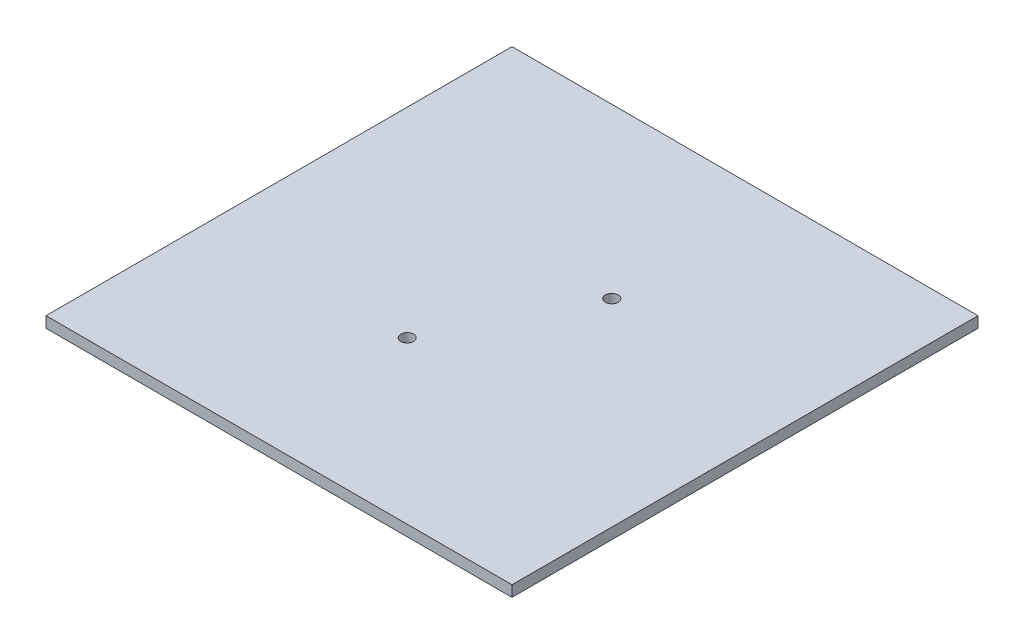
from build123d import *

# Parameters (mm, degrees)
SKETCH1_W             = 101.6
SKETCH1_H             = 101.6
BOSS_EXTRUDE1_DEPTH   = 2.38125
F_2_5MM_DOWEL_HOLE1_D = 2.794


with BuildPart() as part:
    # Sketch1 → Boss-Extrude1 (new body)
    with BuildSketch(Plane.XZ.offset(-61.790986141)):
        Rectangle(SKETCH1_W, SKETCH1_H)
    extrude(amount=BOSS_EXTRUDE1_DEPTH)

    # Ø2.5mm Dowel Hole1 (through all)
    with Locations(Plane(origin=(0, 59.409736141, 0), x_dir=(-1, 0, 0), z_dir=(0, -1, 0))):
        with Locations((7.25, -15.6), (-7.65, 14.1)):
            Hole(F_2_5MM_DOWEL_HOLE1_D / 2)


solid = part.part
